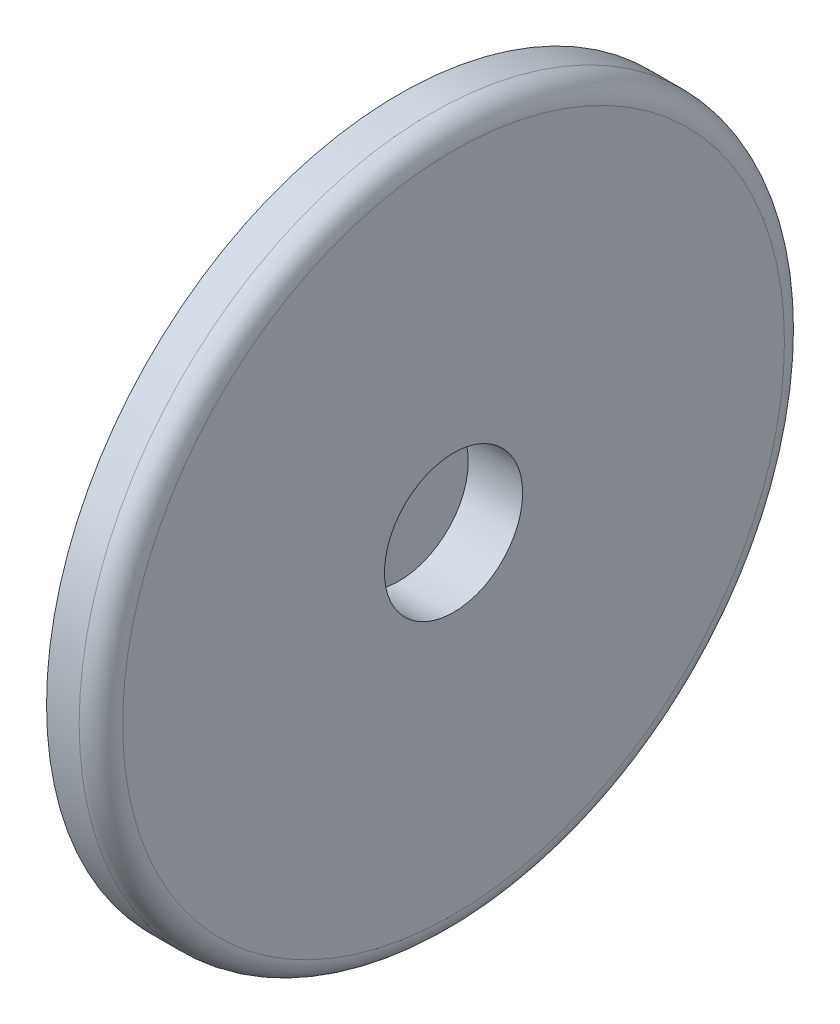
from build123d import *

# Parameters (mm, degrees)
SKETCH1_R           = 51.15
BOSS_EXTRUDE1_DEPTH = 10
SKETCH2_R           = 64.84855049
BOSS_EXTRUDE2_DEPTH = 10
SKETCH3_R           = 12.7
CUT_EXTRUDE1_DEPTH  = 10
FILLET1_R           = 1
FILLET2_R           = 4


with BuildPart() as part:
    # Sketch1 → Boss-Extrude1 (new body)
    with BuildSketch(Plane(origin=(0, 0, 0), x_dir=(0, 0, -1), z_dir=(1, 0, 0))):
        Circle(SKETCH1_R)
    extrude(amount=BOSS_EXTRUDE1_DEPTH)

    # Sketch2 → Boss-Extrude2 (add)
    with BuildSketch(Plane(origin=(10, 0, 0), x_dir=(0, 0, -1), z_dir=(1, 0, 0))):
        Circle(SKETCH2_R)
    extrude(amount=BOSS_EXTRUDE2_DEPTH)

    # Sketch3 → Cut-Extrude1 (cut)
    with BuildSketch(Plane(origin=(20, 0, 0), x_dir=(0, 0, -1), z_dir=(1, 0, 0))):
        Circle(SKETCH3_R)
    extrude(amount=-CUT_EXTRUDE1_DEPTH, mode=Mode.SUBTRACT)

    # Fillet1
    fillet1_edges = [part.edges().sort_by_distance(p)[0] for p in [
        (0, 0, 51.15),
    ]]
    fillet(fillet1_edges, radius=FILLET1_R)

    # Fillet2
    fillet2_edges = [part.edges().sort_by_distance(p)[0] for p in [
        (20, 0, 64.84855049),
    ]]
    fillet(fillet2_edges, radius=FILLET2_R)


solid = part.part
